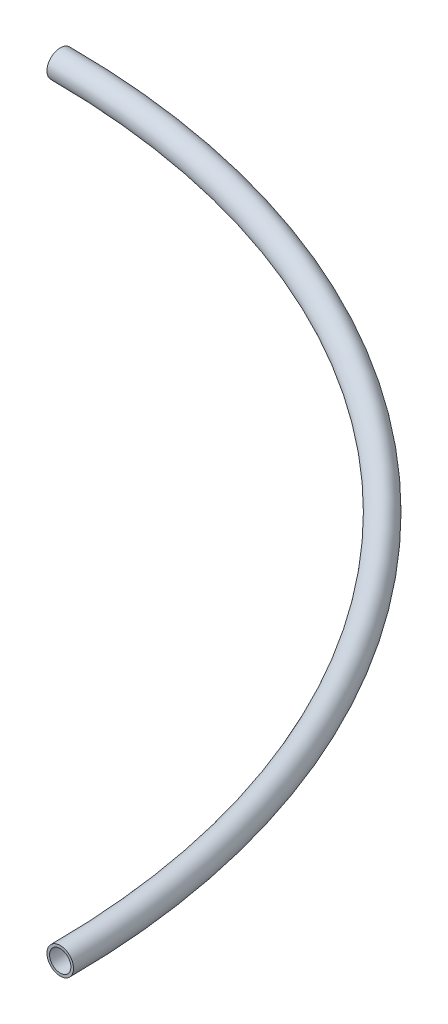
from build123d import *

# Parameters (mm, degrees)
SKETCH1_R      = 25
SKETCH1_R_2    = 20
REVOLVE1_ANGLE = 90


with BuildPart() as part:
    # Sketch1 → Revolve1 (revolve)
    with BuildSketch(Plane.XY):
        with Locations((1460, 0)):
            Circle(SKETCH1_R)
        with Locations((1460, 0)):
            Circle(SKETCH1_R_2, mode=Mode.SUBTRACT)
    revolve(axis=Axis((0, 0, 0), (0, 1, 0)), revolution_arc=REVOLVE1_ANGLE)


solid = part.part
